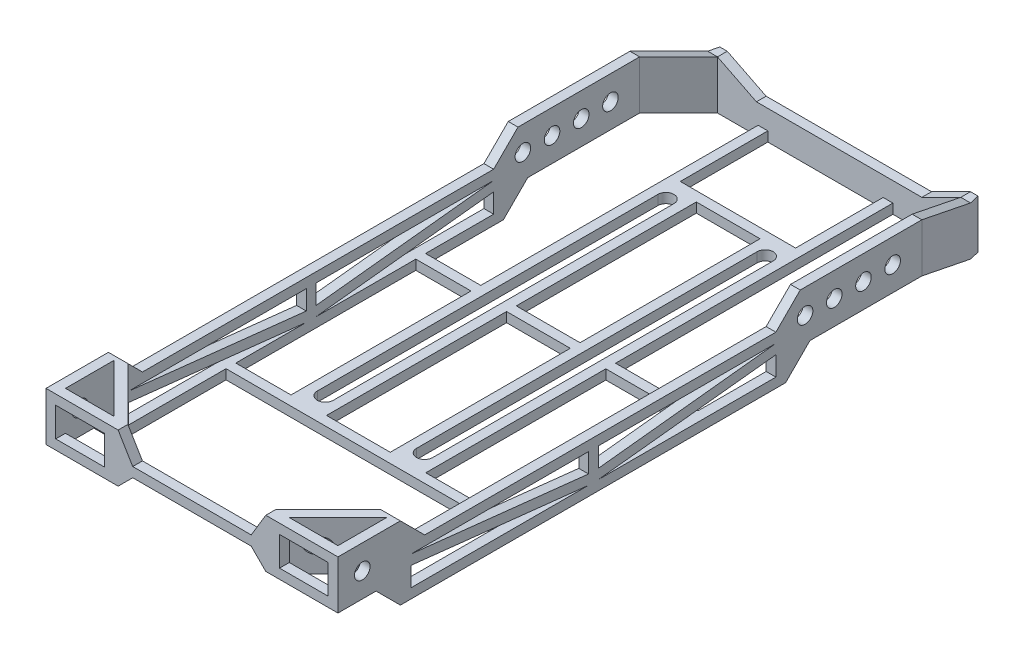
from build123d import *

# Parameters (mm, degrees)
BOSS_EXTRUDE1_DEPTH = 12.7
CUT_EXTRUDE3_DEPTH  = 77.2
SKETCH8_W           = 71.12
SKETCH8_H           = 101.6
BOSS_EXTRUDE3_DEPTH = 2.54
SKETCH9_W           = 14.4145
SKETCH9_H           = 99.06
SKETCH9_W_2         = 21.5265
SKETCH9_H_2         = 49.53
SKETCH9_W_3         = 16.637
SKETCH9_H_3         = 46.99
CUT_EXTRUDE4_DEPTH  = 2.54
BOSS_EXTRUDE4_DEPTH = 12.7
SKETCH19_W          = 2.54
SKETCH19_H          = 2.54
BOSS_EXTRUDE6_DEPTH = 25.4
BOSS_EXTRUDE7_DEPTH = 6.35
BOSS_EXTRUDE8_DEPTH = 6.35
CUT_EXTRUDE9_DEPTH  = 77.2
CUT_EXTRUDE10_DEPTH = 2.54
SKETCH28_W          = 12.7
SKETCH28_H          = 7.62
CUT_EXTRUDE11_DEPTH = 2.54
CUT_EXTRUDE12_DEPTH = 12.7
CUT_EXTRUDE13_DEPTH = 12.7
SKETCH32_R          = 2.032
CUT_EXTRUDE15_DEPTH = 77.2
SKETCH33_W          = 2.54
SKETCH33_H          = 2.54
BOSS_EXTRUDE9_DEPTH = 15.24
CUT_EXTRUDE17_DEPTH = 2.54


with BuildPart() as part:
    # Sketch1 → Boss-Extrude1 (new body)
    with BuildSketch(Plane(origin=(0, 0, 0), x_dir=(1, 0, 0), z_dir=(0, 1, 0))):
        Polygon((38.1, -76.2), (38.1, 76.2), (35.56, 76.2), (35.56, -57.367897552), (19.267897552, -73.66), (-19.267897552, -73.66), (-35.56, -57.367897552), (-35.56, 76.2), (-38.1, 76.2), (-38.1, -76.2), align=None)
        Polygon((-35.56, -73.66), (-22.86, -73.66), (-35.56, -60.96), align=None, mode=Mode.SUBTRACT)
        Polygon((22.86, -73.66), (35.56, -60.96), (35.56, -73.66), align=None, mode=Mode.SUBTRACT)
    extrude(amount=BOSS_EXTRUDE1_DEPTH)

    # Sketch7 → Cut-Extrude3 (cut, through all)
    with BuildSketch(Plane(origin=(38.1, 0, 0), x_dir=(0, 0, -1), z_dir=(1, 0, 0))):
        Polygon((-57.15, 10.16), (-10.795093656, 10.16), (-10.795093656, 5.095127003), align=None)
        Polygon((-57.15, 7.60488323), (-57.15, 2.54), (-10.795, 2.54), align=None)
        Polygon((-8.255093656, 10.16), (38.1, 10.16), (-8.255093656, 5.095106537), align=None)
        Polygon((-8.255, 2.54), (38.1, 2.54), (38.1, 7.60488323), align=None)
    extrude(amount=-CUT_EXTRUDE3_DEPTH, mode=Mode.SUBTRACT)

    # Sketch8 → Boss-Extrude3 (add)
    with BuildSketch(Plane.XZ):
        with Locations((0, -19.05)):
            Rectangle(SKETCH8_W, SKETCH8_H)
    extrude(amount=-BOSS_EXTRUDE3_DEPTH)

    # Sketch9 → Cut-Extrude4 (cut)
    with BuildSketch(Plane(origin=(0, 2.54, 0), x_dir=(1, 0, 0), z_dir=(0, 1, 0))):
        with Locations((-28.35275, 20.32)):
            Rectangle(SKETCH9_W, SKETCH9_H)
        with BuildLine():
            Line((-14.4145, 64.008), (-14.4145, -24.892))
            ThreePointArc((-14.4145, -24.892), (-16.51, -26.9875), (-18.6055, -24.892))
            Line((-18.6055, -24.892), (-18.6055, 64.008))
            ThreePointArc((-18.6055, 64.008), (-16.51, 66.1035), (-14.4145, 64.008))
        make_face()
        with Locations((24.79675, 45.085)):
            Rectangle(SKETCH9_W_2, SKETCH9_H_2)
        with Locations((-3.556, 43.815)):
            Rectangle(SKETCH9_W_3, SKETCH9_H_3)
        with BuildLine():
            Line((7.3025, 64.008), (7.3025, -24.892))
            ThreePointArc((7.3025, -24.892), (9.398, -26.9875), (11.4935, -24.892))
            Line((11.4935, -24.892), (11.4935, 64.008))
            ThreePointArc((11.4935, 64.008), (9.398, 66.1035), (7.3025, 64.008))
        make_face()
        with Locations((-3.556, -5.715)):
            Rectangle(SKETCH9_W_3, SKETCH9_H_3)
        with Locations((24.79675, -5.715)):
            Rectangle(SKETCH9_W_2, SKETCH9_H_3)
    extrude(amount=-CUT_EXTRUDE4_DEPTH, mode=Mode.SUBTRACT)

    # Sketch16 → Boss-Extrude4 (add)
    with BuildSketch(Plane.XZ):
        Polygon((-35.56, -76.2), (-31.75, -92.71), (31.75, -92.71), (35.56, -76.2), (38.1, -76.2), (33.703846154, -95.25), (-33.703846154, -95.25), (-38.1, -76.2), align=None)
    extrude(amount=-BOSS_EXTRUDE4_DEPTH)

    # Sketch19 → Boss-Extrude6 (add)
    with BuildSketch(Plane(origin=(0, 0, -69.85), x_dir=(-1, 0, 0), z_dir=(0, 0, -1))):
        with Locations((19.8755, 1.27)):
            Rectangle(SKETCH19_W, SKETCH19_H)
        with Locations((-12.7635, 1.27)):
            Rectangle(SKETCH19_W, SKETCH19_H)
    extrude(amount=BOSS_EXTRUDE6_DEPTH)

    # Sketch21 → Boss-Extrude7 (add)
    with BuildSketch(Plane(origin=(0, 12.7, 0), x_dir=(1, 0, 0), z_dir=(0, 1, 0))):
        Polygon((38.1, 38.1), (38.1, 76.2), (33.703846154, 95.25), (31.75, 92.71), (35.56, 76.2), (35.56, 38.1), align=None)
        Polygon((-35.56, 38.1), (-38.1, 38.1), (-38.1, 76.2), (-33.703846154, 95.25), (-31.75, 92.71), (-35.56, 76.2), align=None)
    extrude(amount=BOSS_EXTRUDE7_DEPTH)

    # Sketch24 → Boss-Extrude8 (add)
    with BuildSketch(Plane(origin=(0, 12.7, 0), x_dir=(1, 0, 0), z_dir=(0, 1, 0))):
        Polygon((-38.1, -57.367897552), (-38.1, -76.2), (-19.267897552, -76.2), (-15.457897552, -76.2), (-15.457897552, -73.66), (-19.267897552, -73.66), (-35.56, -57.367897552), (-35.56, -53.557897552), (-38.1, -53.557897552), align=None)
        Polygon((-22.86, -73.66), (-35.56, -60.96), (-35.56, -73.66), align=None, mode=Mode.SUBTRACT)
        Polygon((19.267897552, -76.2), (38.1, -76.2), (38.1, -57.367897552), (38.1, -53.557897552), (35.56, -53.557897552), (35.56, -57.367897552), (19.267897552, -73.66), (15.457897552, -73.66), (15.457897552, -76.2), align=None)
        Polygon((22.86, -73.66), (35.56, -60.96), (35.56, -73.66), align=None, mode=Mode.SUBTRACT)
    extrude(amount=BOSS_EXTRUDE8_DEPTH)

    # Sketch26 → Cut-Extrude9 (cut, through all)
    with BuildSketch(Plane(origin=(38.1, 0, 0), x_dir=(0, 0, -1), z_dir=(1, 0, 0))):
        Polygon((-53.557897552, 12.7), (-59.907897552, 19.05), (-53.557897552, 19.05), align=None)
        Polygon((-59.907897552, 0), (-66.257897552, 6.35), (-76.2, 6.35), (-76.2, 0), align=None)
    extrude(amount=-CUT_EXTRUDE9_DEPTH, mode=Mode.SUBTRACT)

    # Sketch27 → Cut-Extrude10 (cut)
    with BuildSketch(Plane.XY.offset(76.2)):
        Polygon((-15.457897552, 12.7), (-19.267897552, 19.05), (-15.457897552, 19.05), align=None)
        Polygon((15.457897552, 12.7), (15.457897552, 19.05), (19.267897552, 19.05), align=None)
        Polygon((-19.267897552, 6.35), (-15.457897552, 10.16), (15.457897552, 10.16), (19.267897552, 6.35), align=None)
    extrude(amount=-CUT_EXTRUDE10_DEPTH, mode=Mode.SUBTRACT)

    # Sketch28 → Cut-Extrude11 (cut)
    with BuildSketch(Plane.XY.offset(76.2)):
        with Locations((-29.21, 12.7)):
            Rectangle(SKETCH28_W, SKETCH28_H)
        with Locations((29.21, 12.7)):
            Rectangle(SKETCH28_W, SKETCH28_H)
    extrude(amount=-CUT_EXTRUDE11_DEPTH, mode=Mode.SUBTRACT)

    # Sketch29 → Cut-Extrude12 (cut)
    with BuildSketch(Plane(origin=(38.1, 0, 0), x_dir=(0, 0, -1), z_dir=(1, 0, 0))):
        Polygon((38.1, 12.7), (44.45, 19.05), (38.1, 19.05), align=None)
        Polygon((40.64, 0), (46.99, 6.35), (76.2, 6.35), (92.71, 0), align=None)
        Polygon((76.2, 19.05), (92.71, 12.7), (95.25, 12.7), (95.25, 19.05), align=None)
    extrude(amount=-CUT_EXTRUDE12_DEPTH, mode=Mode.SUBTRACT)

    # Sketch30 → Cut-Extrude13 (cut)
    with BuildSketch(Plane.ZY.offset(38.1)):
        Polygon((-38.1, 12.7), (-44.45, 19.05), (-38.1, 19.05), align=None)
        Polygon((-46.99, 6.35), (-40.64, 0), (-92.71, 0), (-76.2, 6.35), align=None)
        Polygon((-76.2, 19.05), (-92.71, 12.7), (-95.25, 12.7), (-95.25, 19.05), align=None)
    extrude(amount=-CUT_EXTRUDE13_DEPTH, mode=Mode.SUBTRACT)

    # Sketch32 → Cut-Extrude15 (cut, through all)
    with BuildSketch(Plane(origin=(38.1, 0, 0), x_dir=(0, 0, -1), z_dir=(1, 0, 0))):
        with Locations((45.72, 12.7)):
            Circle(SKETCH32_R)
        with Locations((53.34, 12.7)):
            Circle(SKETCH32_R)
        with Locations((60.96, 12.7)):
            Circle(SKETCH32_R)
        with Locations((68.58, 12.7)):
            Circle(SKETCH32_R)
        with Locations(Location((-69.85, 12.7, 0), (0, 0, 180))):  # turned: the seam where the file's is
            Circle(SKETCH32_R)
    extrude(amount=-CUT_EXTRUDE15_DEPTH, mode=Mode.SUBTRACT)

    # Sketch33 → Boss-Extrude9 (add)
    with BuildSketch(Plane.ZY.offset(21.1455)):
        with Locations((-19.05, 1.27)):
            Rectangle(SKETCH33_W, SKETCH33_H)
    extrude(amount=BOSS_EXTRUDE9_DEPTH)

    # Sketch35 → Cut-Extrude17 (cut)
    with BuildSketch(Plane.XY.offset(-92.71)):
        Polygon((-31.75, 12.7), (-21.59, 7.62), (21.59, 7.62), (31.75, 12.7), align=None)
    extrude(amount=-CUT_EXTRUDE17_DEPTH, mode=Mode.SUBTRACT)


solid = part.part
